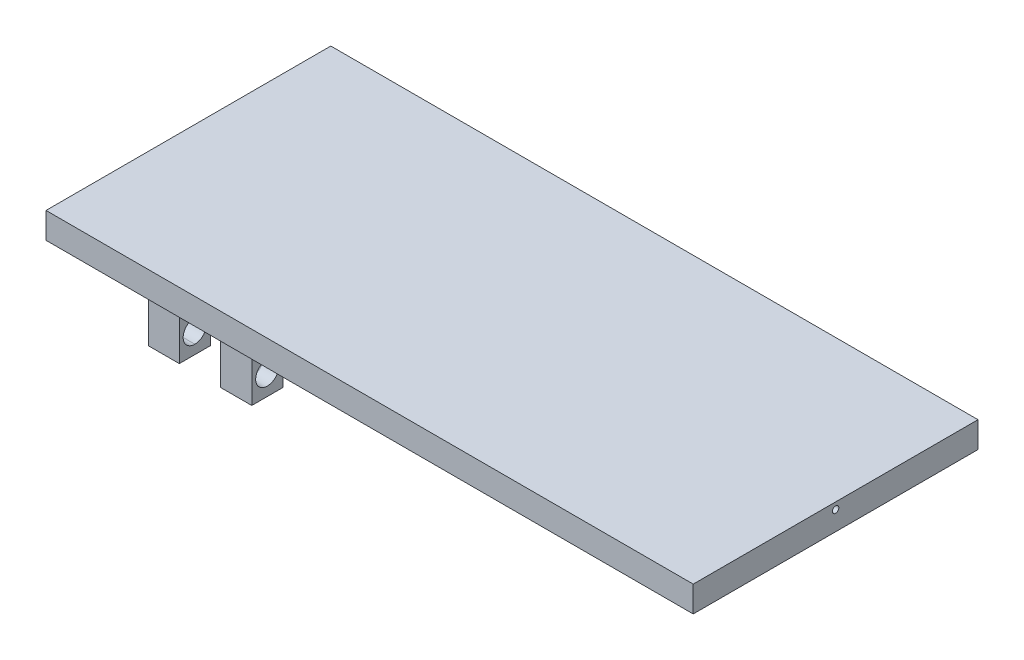
from build123d import *

# Parameters (mm, degrees)
BOSS_EXTRUDE1_DEPTH                 = 5
SKETCH3_W                           = 6
SKETCH3_H                           = 6
BOSS_EXTRUDE2_DEPTH                 = 15
F_8_CLEARANCE_HOLE2_D               = 4.4958
F_8_CLEARANCE_HOLE2_DEPTH           = 17
F_8_CLEARANCE_HOLE2_TIP             = 1.350674586
F_8_CLEARANCE_HOLE2_ON_FACE_2_D     = 4.4958
F_8_CLEARANCE_HOLE2_ON_FACE_2_DEPTH = 17
F_8_CLEARANCE_HOLE2_ON_FACE_2_TIP   = 1.350674586
SKETCH17_R                          = 0.625
CUT_EXTRUDE1_DEPTH                  = 30


with BuildPart() as part:
    # Sketch1 → Boss-Extrude1 (new body)
    with BuildSketch(Plane(origin=(0, 0, 0), x_dir=(1, 0, 0), z_dir=(0, 1, 0))):
        Polygon((-14.338976611, 0), (110.661023389, 0), (110.661023389, 55), (8.161023389, 55), (-14.338976611, 55), align=None)
    extrude(amount=BOSS_EXTRUDE1_DEPTH)

    # Sketch3 → Boss-Extrude2 (add)
    with BuildSketch(Plane(origin=(0, 0, 0), x_dir=(-1, 0, 0), z_dir=(0, -1, 0))):
        with Locations((-1.161023389, 44.75)):
            Rectangle(SKETCH3_W, SKETCH3_H)
        with Locations((-1.161023389, 10.25)):
            Rectangle(SKETCH3_W, SKETCH3_H)
        with Locations((-15.161023389, 44.934631069)):
            Rectangle(SKETCH3_W, SKETCH3_H)
        with Locations((-15.161023389, 10.240172473)):
            Rectangle(SKETCH3_W, SKETCH3_H)
    extrude(amount=BOSS_EXTRUDE2_DEPTH)

    # #8 Clearance Hole2
    with Locations(Plane(origin=(-1.838976611, -11, -44.75), x_dir=(0, 0, -1), z_dir=(-1, 0, 0))):
        with Locations((0, 0), (-34.5, 0)):
            Hole(F_8_CLEARANCE_HOLE2_D / 2, depth=F_8_CLEARANCE_HOLE2_DEPTH)
            with Locations((0, 0, -(F_8_CLEARANCE_HOLE2_DEPTH + F_8_CLEARANCE_HOLE2_TIP / 2))):  # 118° drill point
                Cone(0, F_8_CLEARANCE_HOLE2_D / 2, F_8_CLEARANCE_HOLE2_TIP, mode=Mode.SUBTRACT)

    # #8 Clearance Hole2 on face 2
    with Locations(Plane(origin=(18.161023389, -11, -44.934631069), x_dir=(0, 0, 1), z_dir=(1, 0, 0))):
        with Locations((0, 0), (34.694458596, 0)):
            Hole(F_8_CLEARANCE_HOLE2_ON_FACE_2_D / 2, depth=F_8_CLEARANCE_HOLE2_ON_FACE_2_DEPTH)
            with Locations((0, 0, -(F_8_CLEARANCE_HOLE2_ON_FACE_2_DEPTH + F_8_CLEARANCE_HOLE2_ON_FACE_2_TIP / 2))):  # 118° drill point
                Cone(0, F_8_CLEARANCE_HOLE2_ON_FACE_2_D / 2, F_8_CLEARANCE_HOLE2_ON_FACE_2_TIP, mode=Mode.SUBTRACT)

    # Sketch17 → Cut-Extrude1 (cut)
    with BuildSketch(Plane(origin=(110.661023389, 0, 0), x_dir=(0, 0, -1), z_dir=(1, 0, 0))):
        with Locations((27.5, 3.712457307)):
            Circle(SKETCH17_R)
    extrude(amount=-CUT_EXTRUDE1_DEPTH, mode=Mode.SUBTRACT)


solid = part.part
